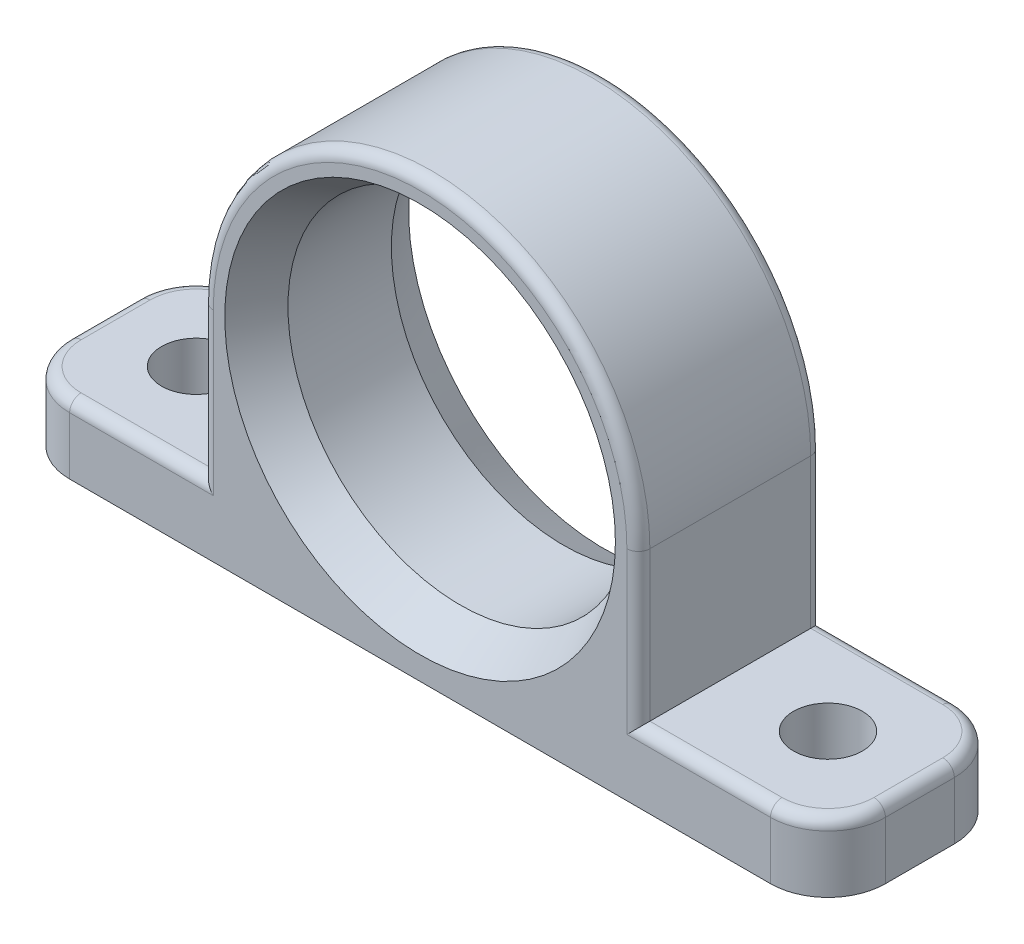
from build123d import *

# Parameters (mm, degrees)
SKETCH1_R               = 15
BOSS_EXTRUDE1_DEPTH     = 16
FILLET1_R               = 5
SKETCH2_R               = 3
CUT_EXTRUDE1_DEPTH      = 33
CUT_EXTRUDE1_DEPTH_BACK = 7
CHAMFER1_SIZE           = 2
CHAMFER1_SIZE2          = 3.5
CHAMFER2_SIZE           = 3.5
CHAMFER2_SIZE2          = 2
FILLET2_R               = 1


with BuildPart() as part:
    # Sketch1 → Boss-Extrude1 (new body)
    with BuildSketch(Plane.XY):
        with BuildLine():
            Line((-35.5, 0), (35.5, 0))
            Line((35.5, 0), (35.5, 6))
            Line((35.5, 6), (19, 6))
            Line((19, 6), (19, 19))
            ThreePointArc((19, 19), (0, 38), (-19, 19))
            Line((-19, 19), (-19, 6))
            Line((-19, 6), (-35.5, 6))
            Line((-35.5, 6), (-35.5, 0))
        make_face()
        with Locations((0, 19)):
            Circle(SKETCH1_R, mode=Mode.SUBTRACT)
    extrude(amount=BOSS_EXTRUDE1_DEPTH)

    # Fillet1
    fillet1_edges = [part.edges().sort_by_distance(p)[0] for p in [
        (35.5, 3, 0),
        (-35.5, 3, 16),
        (35.5, 3, 16),
        (-35.5, 3, 0),
    ]]
    fillet(fillet1_edges, radius=FILLET1_R)

    # Sketch2 → Cut-Extrude1 (cut, two sides)
    with BuildSketch(Plane(origin=(0, 6, 0), x_dir=(1, 0, 0), z_dir=(0, 1, 0))) as cut_extrude1_sk:
        with Locations((-27.5, -8)):
            Circle(SKETCH2_R)
        with Locations((27.5, -8)):
            Circle(SKETCH2_R)
    extrude(amount=CUT_EXTRUDE1_DEPTH, mode=Mode.SUBTRACT)
    extrude(cut_extrude1_sk.sketch, amount=-CUT_EXTRUDE1_DEPTH_BACK, mode=Mode.SUBTRACT)

    # Chamfer1
    chamfer1_edges = [part.edges().sort_by_distance(p)[0] for p in [
        (-15, 19, 16),
    ]]
    chamfer1_side = [part.faces().sort_by_distance(p)[0] for p in [
        (0, 0.718679344, 16),
    ]]
    chamfer(chamfer1_edges, length=CHAMFER1_SIZE, length2=CHAMFER1_SIZE2, reference=chamfer1_side[0])

    # Chamfer2
    chamfer2_edges = [part.edges().sort_by_distance(p)[0] for p in [
        (-15, 19, 0),
    ]]
    chamfer2_side = [part.faces().sort_by_distance(p)[0] for p in [
        (-15, 19, 6.25),
    ]]
    chamfer(chamfer2_edges, length=CHAMFER2_SIZE, length2=CHAMFER2_SIZE2, reference=chamfer2_side[0])

    # Fillet2
    fillet2_edges = [part.edges().sort_by_distance(p)[0] for p in [
        (0, 38, 0),
        (19, 12.5, 0),
        (19, 12.5, 16),
        (0, 38, 16),
        (-19, 12.5, 16),
        (-24.75, 6, 16),
        (-35.5, 6, 8),
        (24.75, 6, 0),
        (-34.035533906, 6, 14.535533906),
        (-34.035533906, 6, 1.464466094),
        (24.75, 6, 16),
        (35.5, 6, 8),
        (34.035533906, 6, 14.535533906),
        (34.035533906, 6, 1.464466094),
        (-24.75, 6, 0),
        (-19, 12.5, 0),
    ]]
    fillet(fillet2_edges, radius=FILLET2_R)


solid = part.part
